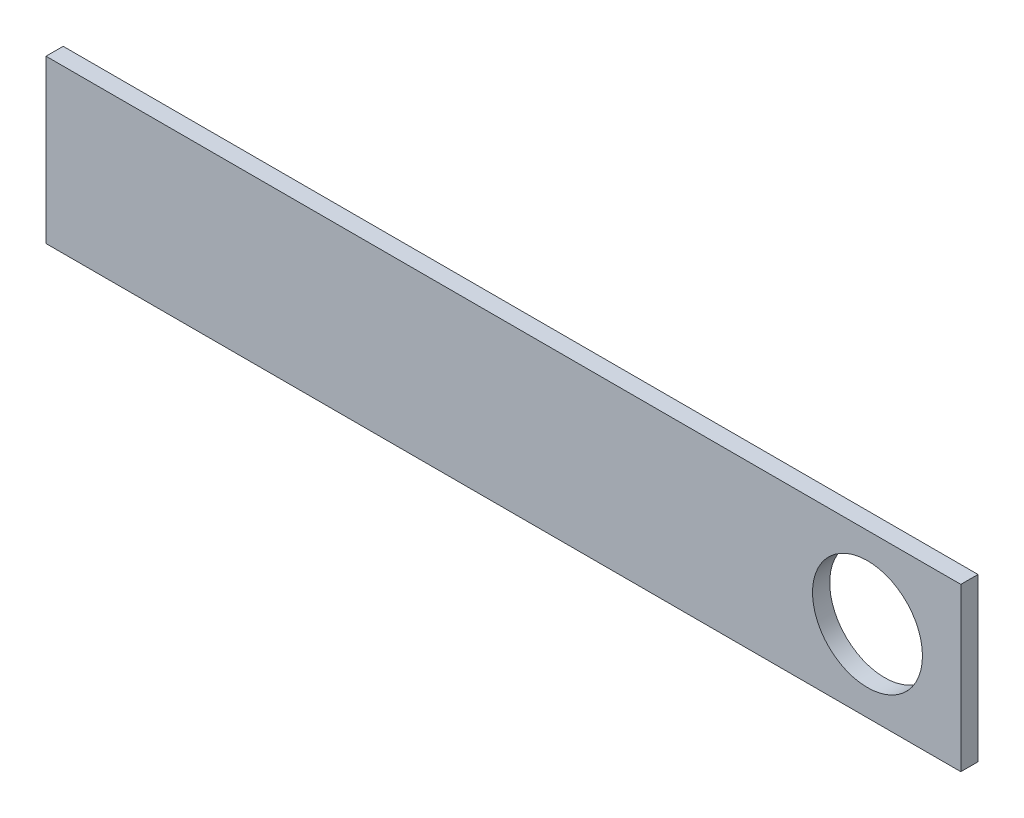
from build123d import *

# Parameters (mm, degrees)
SKETCH1_W           = 135.321335131
SKETCH1_H           = 24.000335308
BOSS_EXTRUDE1_DEPTH = 2.54
SKETCH2_R           = 8.130119586
CUT_EXTRUDE1_DEPTH  = 3.54


with BuildPart() as part:
    # Sketch1 → Boss-Extrude1 (new body)
    with BuildSketch(Plane.XY):
        with Locations((-0.195443485, -60.750472416)):
            Rectangle(SKETCH1_W, SKETCH1_H)
    extrude(amount=-BOSS_EXTRUDE1_DEPTH)

    # Sketch2 → Cut-Extrude1 (cut, through all)
    with BuildSketch(Plane.XY):
        with Locations((53.659302676, -60.750472416)):
            Circle(SKETCH2_R)
    extrude(amount=-CUT_EXTRUDE1_DEPTH, mode=Mode.SUBTRACT)


solid = part.part
